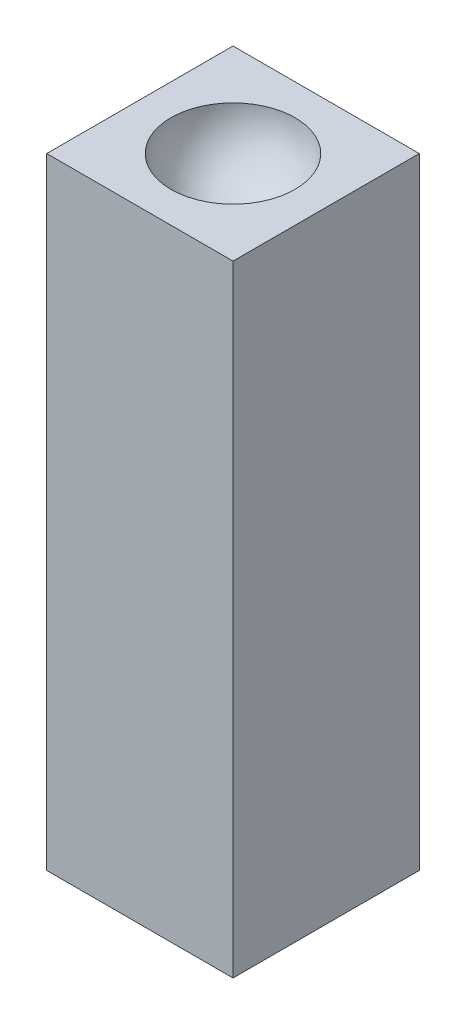
from build123d import *

# Parameters (mm, degrees)
SKETCH1_W           = 6
SKETCH1_H           = 6
BOSS_EXTRUDE1_DEPTH = 20


with BuildPart() as part:
    # Sketch1 → Boss-Extrude1 (new body)
    with BuildSketch(Plane(origin=(0, 0, 0), x_dir=(1, 0, 0), z_dir=(0, 1, 0))):
        Rectangle(SKETCH1_W, SKETCH1_H)
    extrude(amount=BOSS_EXTRUDE1_DEPTH)

    # Sketch3 → Cut-Revolve1 (revolve, cut)
    with BuildSketch(Plane(origin=(0, 20, 0), x_dir=(1, 0, 0), z_dir=(0, 1, 0))):
        with BuildLine():
            Line((-2, 0), (2, 0))
            ThreePointArc((2, 0), (0, 2), (-2, 0))
        make_face()
    revolve(axis=Axis((-2, 20, 0), (1, 0, 0)), mode=Mode.SUBTRACT)


solid = part.part
